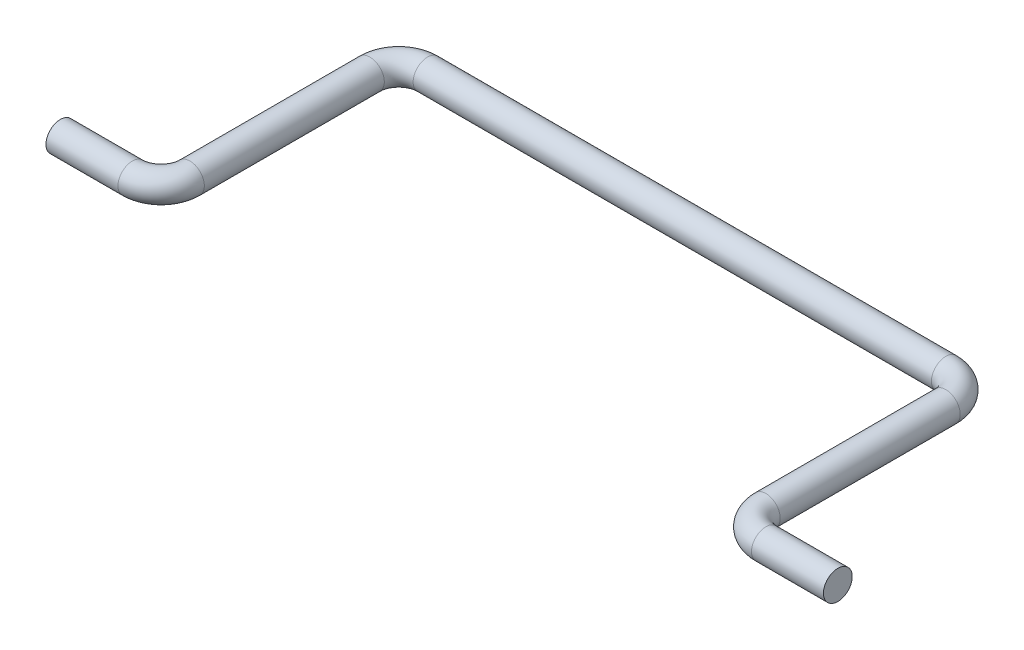
from build123d import *

# Parameters (mm, degrees)
SKETCH4_R = 0.5


with BuildPart() as part:
    # Sweep1: sweep along a path in Sketch1
    with BuildLine(Plane(origin=(0, 0, 0), x_dir=(1, 0, 0), z_dir=(0, 1, 0))) as sweep1_path:
        Line((-13.5, 0), (-11, 0))
        ThreePointArc((-11, 0), (-10.292893219, 0.292893219), (-10, 1))
        Line((-10, 1), (-10, 7.25))
        ThreePointArc((-10, 7.25), (-9.707106781, 7.957106781), (-9, 8.25))
        Line((-9, 8.25), (9, 8.25))
        ThreePointArc((9, 8.25), (9.707106781, 7.957106781), (10, 7.25))
        Line((10, 7.25), (10, 1))
        ThreePointArc((10, 1), (10.292893219, 0.292893219), (11, 0))
        Line((11, 0), (13.5, 0))
    # Sketch4 → Sweep1 (sweep)
    with BuildSketch(Plane(origin=(-13.5, 0, 0), x_dir=(0, 0, -1), z_dir=(1, 0, 0))):
        Circle(SKETCH4_R)
    sweep(path=sweep1_path.line)


solid = part.part
